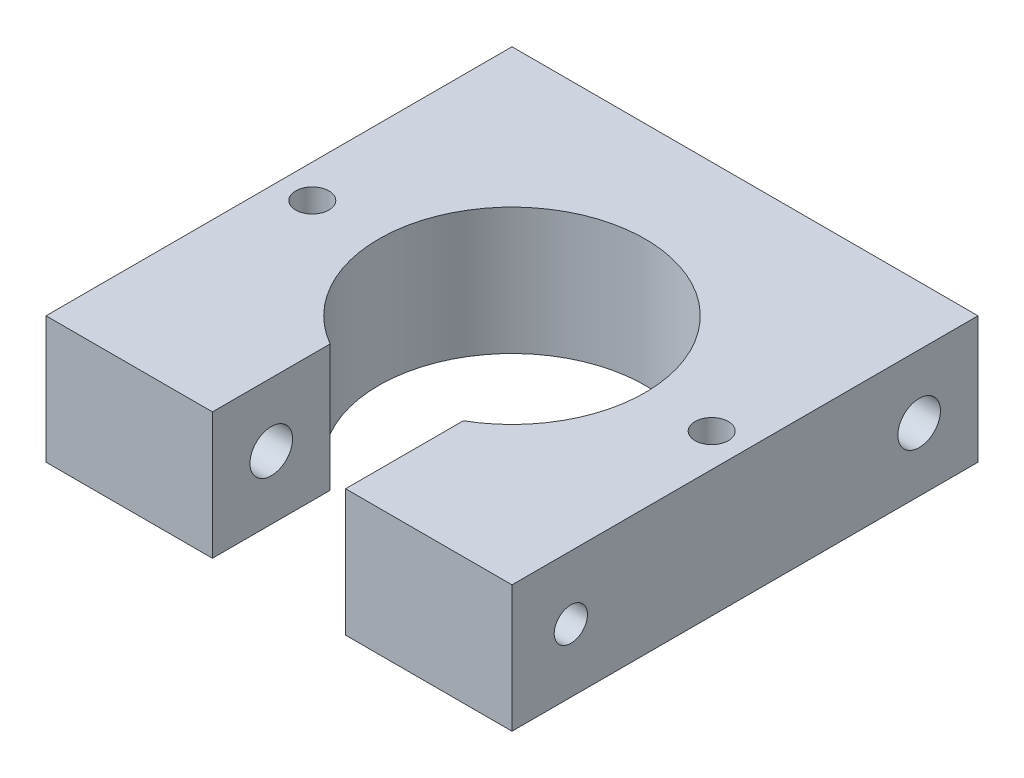
from build123d import *

# Parameters (mm, degrees)
BOSS_EXTRUDE1_DEPTH              = 9.525
TAP_DRILL_FOR_M3X0_5_TAP1_D      = 2.5
TAP_DRILL_FOR_M3X0_5_TAP2_D      = 2.5
TAP_DRILL_FOR_M3X0_5_TAP3_REACH  = 42.274
TAP_DRILL_FOR_M3X0_5_TAP3_BORE_R = 1.25
M3_CLEARANCE_HOLE1_REACH         = 42.274
M3_CLEARANCE_HOLE1_BORE_R        = 1.6


with BuildPart() as part:
    # Sketch1 → Boss-Extrude1 (new body)
    with BuildSketch(Plane(origin=(0, 0, 0), x_dir=(1, 0, 0), z_dir=(0, 1, 0))):
        with BuildLine():
            Line((-17.5, 17.5), (-5, 17.5))
            Line((-5, 17.5), (5, 17.5))
            Line((5, 17.5), (17.5, 17.5))
            Line((17.5, 17.5), (17.5, -17.5))
            Line((17.5, -17.5), (5, -17.5))
            Line((5, -17.5), (5, -8.660254038))
            ThreePointArc((5, -8.660254038), (10, 0), (5, 8.660254038))
            ThreePointArc((5, 8.660254038), (0, 10), (-5, 8.660254038))
            ThreePointArc((-5, 8.660254038), (-10, 0), (-5, -8.660254038))
            Line((-5, -8.660254038), (-5, -17.5))
            Line((-5, -17.5), (-17.5, -17.5))
            Line((-17.5, -17.5), (-17.5, 17.5))
        make_face()
    extrude(amount=BOSS_EXTRUDE1_DEPTH)

    # Tap Drill for M3x0.5 Tap1 (through all)
    with Locations(Plane(origin=(0, 9.525, 0), x_dir=(1, 0, 0), z_dir=(0, 1, 0))):
        with Locations((-15, 0)):
            Hole(TAP_DRILL_FOR_M3X0_5_TAP1_D / 2)

    # Tap Drill for M3x0.5 Tap2 (through all)
    with Locations(Plane(origin=(0, 9.525, 0), x_dir=(1, 0, 0), z_dir=(0, 1, 0))):
        with Locations((15, 0)):
            Hole(TAP_DRILL_FOR_M3X0_5_TAP2_D / 2)

    # Tap Drill for M3x0.5 Tap3 bore → Tap Drill for M3x0.5 Tap3 (cut, up to next)
    with BuildSketch(Plane(origin=(17.5, 0, 0), x_dir=(0, 0, -1), z_dir=(1, 0, 0)), mode=Mode.PRIVATE) as tap_drill_for_m3x0_5_tap3_sk1:
        with Locations((13.08015, 4.7625)):
            Circle(TAP_DRILL_FOR_M3X0_5_TAP3_BORE_R)
    tap_drill_for_m3x0_5_tap3_tool1 = extrude(tap_drill_for_m3x0_5_tap3_sk1.sketch, amount=-TAP_DRILL_FOR_M3X0_5_TAP3_REACH, mode=Mode.PRIVATE) & part.part
    # Tap Drill for M3x0.5 Tap3 bore → Tap Drill for M3x0.5 Tap3 (cut, up to next)
    with BuildSketch(Plane(origin=(17.5, 0, 0), x_dir=(0, 0, -1), z_dir=(1, 0, 0)), mode=Mode.PRIVATE) as tap_drill_for_m3x0_5_tap3_sk2:
        with Locations((-13.08015, 4.7625)):
            Circle(TAP_DRILL_FOR_M3X0_5_TAP3_BORE_R)
    tap_drill_for_m3x0_5_tap3_tool2 = extrude(tap_drill_for_m3x0_5_tap3_sk2.sketch, amount=-TAP_DRILL_FOR_M3X0_5_TAP3_REACH, mode=Mode.PRIVATE) & part.part
    add(tap_drill_for_m3x0_5_tap3_tool1.solids().sort_by_distance((17.5, 4.7625, -13.08015))[0], mode=Mode.SUBTRACT)
    add(tap_drill_for_m3x0_5_tap3_tool2.solids().sort_by_distance((17.5, 4.7625, 13.08015))[0], mode=Mode.SUBTRACT)

    # M3 Clearance Hole1 bore → M3 Clearance Hole1 (cut, up to next)
    with BuildSketch(Plane.ZY.offset(17.5), mode=Mode.PRIVATE) as m3_clearance_hole1_sk1:
        with Locations((-13.08015, 4.7625)):
            Circle(M3_CLEARANCE_HOLE1_BORE_R)
    m3_clearance_hole1_tool1 = extrude(m3_clearance_hole1_sk1.sketch, amount=-M3_CLEARANCE_HOLE1_REACH, mode=Mode.PRIVATE) & part.part
    # M3 Clearance Hole1 bore → M3 Clearance Hole1 (cut, up to next)
    with BuildSketch(Plane.ZY.offset(17.5), mode=Mode.PRIVATE) as m3_clearance_hole1_sk2:
        with Locations((13.08015, 4.7625)):
            Circle(M3_CLEARANCE_HOLE1_BORE_R)
    m3_clearance_hole1_tool2 = extrude(m3_clearance_hole1_sk2.sketch, amount=-M3_CLEARANCE_HOLE1_REACH, mode=Mode.PRIVATE) & part.part
    add(m3_clearance_hole1_tool1.solids().sort_by_distance((-17.5, 4.7625, -13.08015))[0], mode=Mode.SUBTRACT)
    add(m3_clearance_hole1_tool2.solids().sort_by_distance((-17.5, 4.7625, 13.08015))[0], mode=Mode.SUBTRACT)


solid = part.part
